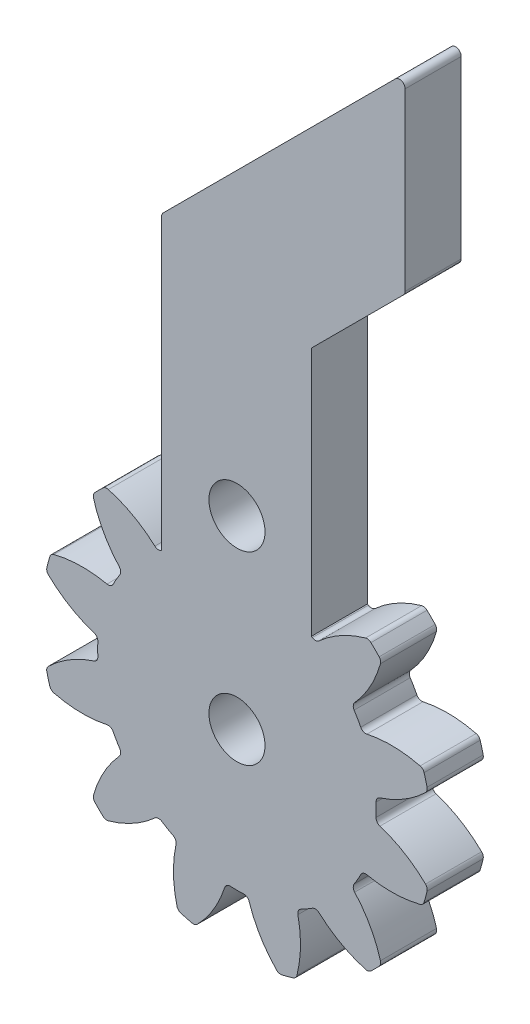
from build123d import *

# Parameters (mm, degrees)
ESQUISSE18_R        = 1.5
BOSS_EXTRU_18_DEPTH = 3
CONG_1_R            = 0.3


with BuildPart() as part:
    # Esquisse18 → Boss.-Extru.18 (new body)
    with BuildSketch(Plane.XY):
        with BuildLine():
            Line((97.025632531, 29.590316063), (83.99617235, 16.560855882))
            Line((83.99617235, 16.560855882), (83.99617235, 0.958265781))
            ThreePointArc((83.99617235, 0.958265781), (83.812104956, 0.91607214), (83.639294573, 0.992214643))
            ThreePointArc((83.639294573, 0.992214643), (82.474359337, 1.824587373), (81.150565301, 2.370011808))
            ThreePointArc((81.150565301, 2.370011808), (80.997528298, 2.372778276), (80.863045123, 2.29968756))
            ThreePointArc((80.863045123, 2.29968756), (80.641045132, 2.084165463), (80.425523035, 1.862165472))
            ThreePointArc((80.425523035, 1.862165472), (80.352432318, 1.727682296), (80.355198786, 1.574645294))
            ThreePointArc((80.355198786, 1.574645294), (80.900623221, 0.250851257), (81.732995951, -0.914083979))
            ThreePointArc((81.732995951, -0.914083979), (81.809478339, -1.090727988), (81.76286699, -1.277489987))
            ThreePointArc((81.76286699, -1.277489987), (81.668844739, -1.427698297), (81.578421737, -1.580100401))
            ThreePointArc((81.578421737, -1.580100401), (81.491649145, -1.734610069), (81.408576058, -1.891139882))
            ThreePointArc((81.408576058, -1.891139882), (81.270141097, -2.024887494), (81.078921703, -2.046973808))
            ThreePointArc((81.078921703, -2.046973808), (79.65387183, -1.908585496), (78.234720348, -2.098131098))
            ThreePointArc((78.234720348, -2.098131098), (78.100803182, -2.172253768), (78.020882694, -2.302793773))
            ThreePointArc((78.020882694, -2.302793773), (77.93638611, -2.600441379), (77.860738495, -2.90046006))
            ThreePointArc((77.860738495, -2.90046006), (77.864681666, -3.053471264), (77.943595998, -3.184621962))
            ThreePointArc((77.943595998, -3.184621962), (79.077844433, -4.058349009), (80.38116798, -4.651026153))
            ThreePointArc((80.38116798, -4.651026153), (80.535725676, -4.765763159), (80.588740063, -4.950809468))
            ThreePointArc((80.588740063, -4.950809468), (80.58241856, -5.127904807), (80.580310995, -5.305100401))
            ThreePointArc((80.580310995, -5.305100401), (80.58241856, -5.482295995), (80.588740063, -5.659391333))
            ThreePointArc((80.588740063, -5.659391333), (80.535725676, -5.844437642), (80.38116798, -5.959174648))
            ThreePointArc((80.38116798, -5.959174648), (79.077844433, -6.551851792), (77.943595998, -7.425578839))
            ThreePointArc((77.943595998, -7.425578839), (77.864681666, -7.556729537), (77.860738495, -7.709740741))
            ThreePointArc((77.860738495, -7.709740741), (77.93638611, -8.009759422), (78.020882694, -8.307407028))
            ThreePointArc((78.020882694, -8.307407028), (78.100803182, -8.437947034), (78.234720348, -8.512069703))
            ThreePointArc((78.234720348, -8.512069703), (79.65387183, -8.701615305), (81.078921703, -8.563226993))
            ThreePointArc((81.078921703, -8.563226993), (81.270141097, -8.585313307), (81.408576058, -8.719060919))
            ThreePointArc((81.408576058, -8.719060919), (81.491649145, -8.875590732), (81.578421737, -9.030100401))
            ThreePointArc((81.578421737, -9.030100401), (81.668844739, -9.182502504), (81.76286699, -9.332710814))
            ThreePointArc((81.76286699, -9.332710814), (81.809478339, -9.519472813), (81.732995951, -9.696116822))
            ThreePointArc((81.732995951, -9.696116822), (80.900623221, -10.861052059), (80.355198786, -12.184846095))
            ThreePointArc((80.355198786, -12.184846095), (80.352432318, -12.337883097), (80.425523035, -12.472366273))
            ThreePointArc((80.425523035, -12.472366273), (80.641045132, -12.694366264), (80.863045123, -12.909888361))
            ThreePointArc((80.863045123, -12.909888361), (80.997528298, -12.982979077), (81.150565301, -12.98021261))
            ThreePointArc((81.150565301, -12.98021261), (82.474359337, -12.434788174), (83.639294573, -11.602415444))
            ThreePointArc((83.639294573, -11.602415444), (83.815938583, -11.525933057), (84.002700581, -11.572544405))
            ThreePointArc((84.002700581, -11.572544405), (84.152908892, -11.666566657), (84.305310995, -11.756989659))
            ThreePointArc((84.305310995, -11.756989659), (84.459820663, -11.843762251), (84.616350477, -11.926835338))
            ThreePointArc((84.616350477, -11.926835338), (84.750098088, -12.065270299), (84.772184402, -12.256489692))
            ThreePointArc((84.772184402, -12.256489692), (84.633796091, -13.681539565), (84.823341693, -15.100691048))
            ThreePointArc((84.823341693, -15.100691048), (84.897464362, -15.234608214), (85.028004367, -15.314528702))
            ThreePointArc((85.028004367, -15.314528702), (85.325651974, -15.399025285), (85.625670654, -15.474672901))
            ThreePointArc((85.625670654, -15.474672901), (85.778681859, -15.47072973), (85.909832557, -15.391815398))
            ThreePointArc((85.909832557, -15.391815398), (86.783559604, -14.257566963), (87.376236747, -12.954243415))
            ThreePointArc((87.376236747, -12.954243415), (87.490973753, -12.79968572), (87.676020063, -12.746671333))
            ThreePointArc((87.676020063, -12.746671333), (87.853115401, -12.752992835), (88.030310995, -12.755100401))
            ThreePointArc((88.030310995, -12.755100401), (88.207506589, -12.752992835), (88.384601928, -12.746671333))
            ThreePointArc((88.384601928, -12.746671333), (88.569648237, -12.79968572), (88.684385243, -12.954243415))
            ThreePointArc((88.684385243, -12.954243415), (89.277062386, -14.257566963), (90.150789434, -15.391815398))
            ThreePointArc((90.150789434, -15.391815398), (90.281940131, -15.47072973), (90.434951336, -15.474672901))
            ThreePointArc((90.434951336, -15.474672901), (90.734970016, -15.399025285), (91.032617623, -15.314528702))
            ThreePointArc((91.032617623, -15.314528702), (91.163157628, -15.234608214), (91.237280298, -15.100691048))
            ThreePointArc((91.237280298, -15.100691048), (91.426825899, -13.681539565), (91.288437588, -12.256489692))
            ThreePointArc((91.288437588, -12.256489692), (91.310523902, -12.065270299), (91.444271513, -11.926835338))
            ThreePointArc((91.444271513, -11.926835338), (91.600801327, -11.843762251), (91.755310995, -11.756989659))
            ThreePointArc((91.755310995, -11.756989659), (91.907713098, -11.666566657), (92.057921409, -11.572544405))
            ThreePointArc((92.057921409, -11.572544405), (92.244683407, -11.525933057), (92.421327417, -11.602415444))
            ThreePointArc((92.421327417, -11.602415444), (93.586262653, -12.434788174), (94.91005669, -12.98021261))
            ThreePointArc((94.91005669, -12.98021261), (95.063093692, -12.982979077), (95.197576867, -12.909888361))
            ThreePointArc((95.197576867, -12.909888361), (95.419576859, -12.694366264), (95.635098955, -12.472366273))
            ThreePointArc((95.635098955, -12.472366273), (95.708189672, -12.337883097), (95.705423204, -12.184846095))
            ThreePointArc((95.705423204, -12.184846095), (95.159998769, -10.861052059), (94.327626039, -9.696116822))
            ThreePointArc((94.327626039, -9.696116822), (94.251143651, -9.519472813), (94.297755, -9.332710814))
            ThreePointArc((94.297755, -9.332710814), (94.391777251, -9.182502504), (94.482200253, -9.030100401))
            ThreePointArc((94.482200253, -9.030100401), (94.568972845, -8.875590732), (94.652045932, -8.719060919))
            ThreePointArc((94.652045932, -8.719060919), (94.790480893, -8.585313307), (94.981700287, -8.563226993))
            ThreePointArc((94.981700287, -8.563226993), (96.40675016, -8.701615305), (97.825901643, -8.512069703))
            ThreePointArc((97.825901643, -8.512069703), (97.959818808, -8.437947034), (98.039739296, -8.307407028))
            ThreePointArc((98.039739296, -8.307407028), (98.12423588, -8.009759422), (98.199883495, -7.709740741))
            ThreePointArc((98.199883495, -7.709740741), (98.195940325, -7.556729537), (98.117025992, -7.425578839))
            ThreePointArc((98.117025992, -7.425578839), (96.982777557, -6.551851792), (95.67945401, -5.959174648))
            ThreePointArc((95.67945401, -5.959174648), (95.524896314, -5.844437642), (95.471881927, -5.659391333))
            ThreePointArc((95.471881927, -5.659391333), (95.47820343, -5.482295994), (95.480310995, -5.305100401))
            ThreePointArc((95.480310995, -5.305100401), (95.47820343, -5.127904807), (95.471881927, -4.950809468))
            ThreePointArc((95.471881927, -4.950809468), (95.524896314, -4.765763159), (95.67945401, -4.651026153))
            ThreePointArc((95.67945401, -4.651026153), (96.982777557, -4.058349009), (98.117025992, -3.184621962))
            ThreePointArc((98.117025992, -3.184621962), (98.195940325, -3.053471264), (98.199883495, -2.90046006))
            ThreePointArc((98.199883495, -2.90046006), (98.12423588, -2.600441379), (98.039739296, -2.302793773))
            ThreePointArc((98.039739296, -2.302793773), (97.959818808, -2.172253768), (97.825901643, -2.098131098))
            ThreePointArc((97.825901643, -2.098131098), (96.40675016, -1.908585496), (94.981700287, -2.046973808))
            ThreePointArc((94.981700287, -2.046973808), (94.790480893, -2.024887494), (94.652045932, -1.891139882))
            ThreePointArc((94.652045932, -1.891139882), (94.568972845, -1.734610069), (94.482200253, -1.580100401))
            ThreePointArc((94.482200253, -1.580100401), (94.391777251, -1.427698297), (94.297755, -1.277489987))
            ThreePointArc((94.297755, -1.277489987), (94.251143651, -1.090727988), (94.327626039, -0.914083979))
            ThreePointArc((94.327626039, -0.914083979), (95.159998769, 0.250851257), (95.705423204, 1.574645294))
            ThreePointArc((95.705423204, 1.574645294), (95.708189672, 1.727682296), (95.635098955, 1.862165472))
            ThreePointArc((95.635098955, 1.862165472), (95.419576859, 2.084165463), (95.197576867, 2.29968756))
            ThreePointArc((95.197576867, 2.29968756), (95.063093692, 2.372778276), (94.91005669, 2.370011808))
            ThreePointArc((94.91005669, 2.370011808), (93.586262653, 1.824587373), (92.421327417, 0.992214643))
            ThreePointArc((92.421327417, 0.992214643), (92.244683407, 0.915732256), (92.057921409, 0.962343604))
            ThreePointArc((92.057921409, 0.962343604), (92.032989683, 0.978295443), (92.007994778, 0.994148104))
            Line((92.007994778, 0.994148104), (92.007994778, 14.347176993))
            Line((92.007994778, 14.347176993), (97.025632531, 19.364814746))
            Line((97.025632531, 19.364814746), (97.025632531, 29.590316063))
        make_face()
        with Locations((88.030310995, -5.305100401)):
            Circle(ESQUISSE18_R, mode=Mode.SUBTRACT)
        with Locations((88.030310995, 4.590763304)):
            Circle(ESQUISSE18_R, mode=Mode.SUBTRACT)
    extrude(amount=BOSS_EXTRU_18_DEPTH)

    # Congé1
    cong_1_edges = [part.edges().sort_by_distance(p)[0] for p in [
        (83.99617235, 16.560855882, 1.5),
        (97.025632531, 29.590316063, 1.5),
        (97.025632531, 19.364814746, 1.5),
    ]]
    fillet(cong_1_edges, radius=CONG_1_R)


solid = part.part
